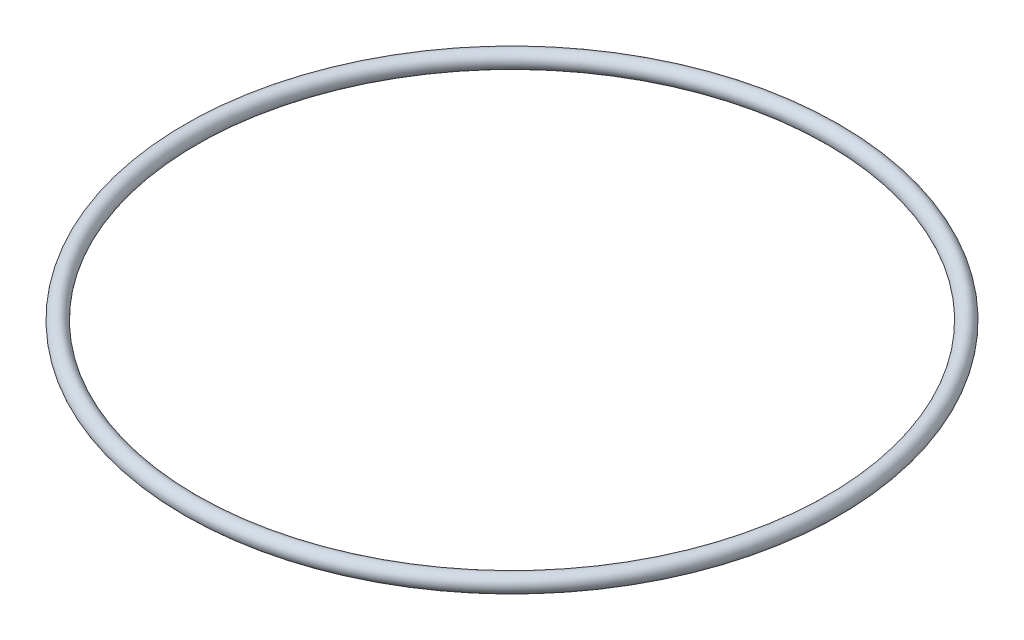
from build123d import *

# Parameters (mm, degrees)
SKETCH1_R = 1.190625


with BuildPart() as part:
    # Sketch1 → Revolve1 (revolve)
    with BuildSketch(Plane.XY):
        with Locations((46.101, 0)):
            Circle(SKETCH1_R)
    revolve(axis=Axis((0, 0, 0), (0, 1, 0)))


solid = part.part
